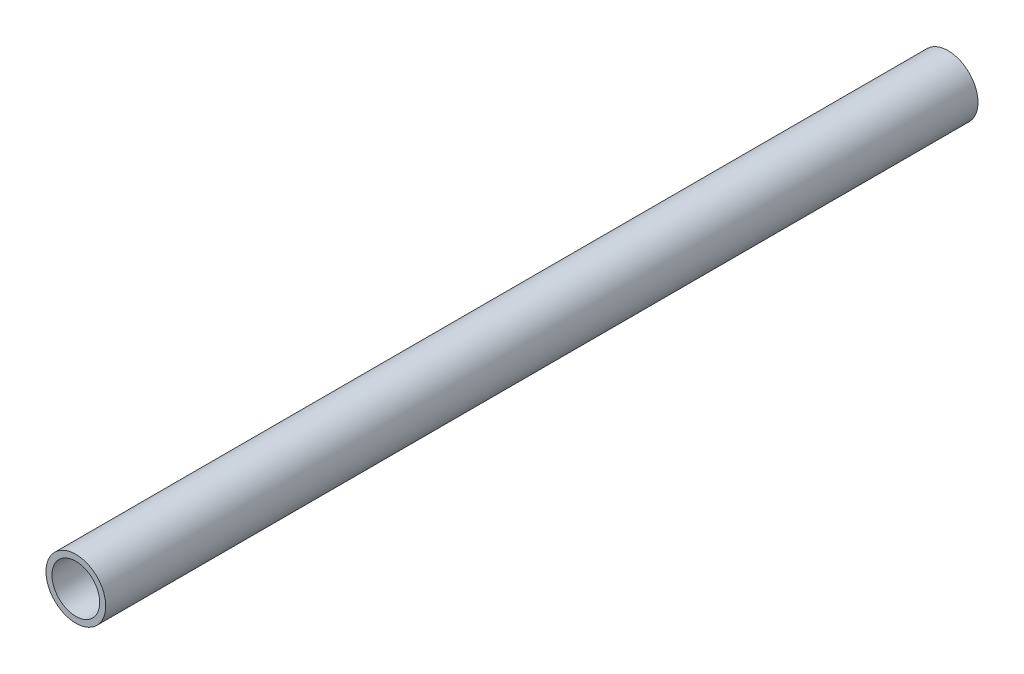
from build123d import *

# Parameters (mm, degrees)
SKETCH_1_R      = 2.5
SKETCH_1_R_2    = 2
EXTRUDE_1_DEPTH = 73


with BuildPart() as part:
    # ｽｹｯﾁ1 → ﾎﾞｽ - 押し出し1 (new body)
    with BuildSketch(Plane.XY):
        Circle(SKETCH_1_R)
        Circle(SKETCH_1_R_2, mode=Mode.SUBTRACT)
    extrude(amount=EXTRUDE_1_DEPTH)


solid = part.part
